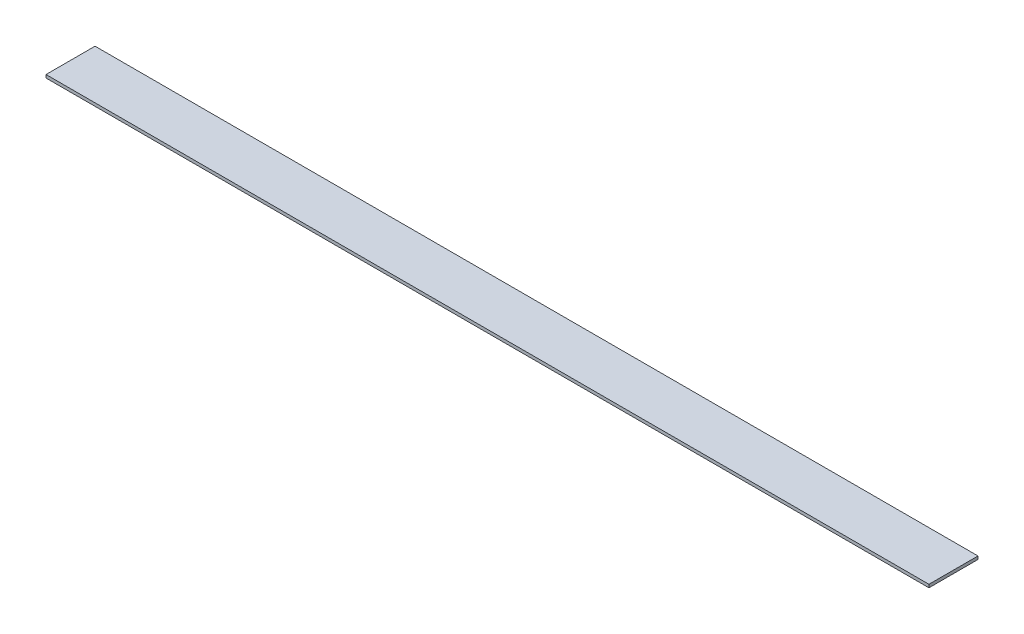
from build123d import *

# Parameters (mm, degrees)
SKETCH1_W           = 457.2
SKETCH1_H           = 25.4
BOSS_EXTRUDE1_DEPTH = 1.5875


with BuildPart() as part:
    # Sketch1 → Boss-Extrude1 (new body)
    with BuildSketch(Plane(origin=(0, 0, 0), x_dir=(1, 0, 0), z_dir=(0, 1, 0))):
        with Locations((228.6, 12.7)):
            Rectangle(SKETCH1_W, SKETCH1_H)
    extrude(amount=BOSS_EXTRUDE1_DEPTH)


solid = part.part
